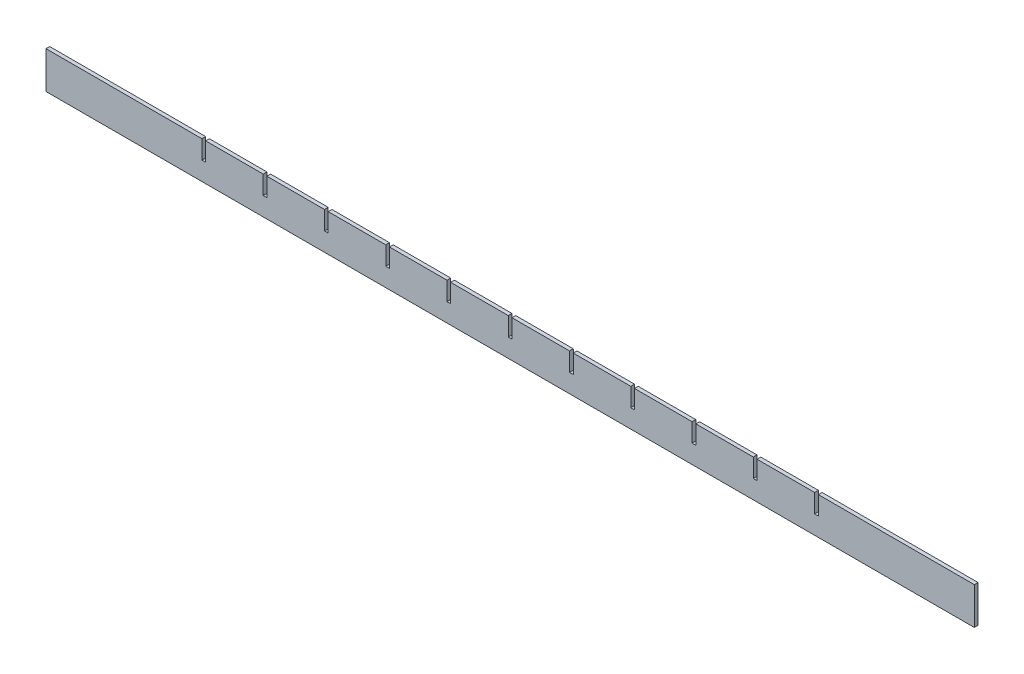
from build123d import *

# Parameters (mm, degrees)
ESQUISSE1_W                = 500
ESQUISSE1_H                = 20
BOSS_EXTRU_1_DEPTH         = 1
ESQUISSE2_W                = 2
ESQUISSE2_H                = 10
ENL_V_MAT_EXTRU_1_DEPTH    = 3
R_P_TITION_LIN_AIRE3_COUNT = 6
R_P_TITION_LIN_AIRE3_PITCH = 33
SYM_TRIE1_COPY_1_SKETCH_W  = 2
SYM_TRIE1_COPY_1_SKETCH_H  = 10
SYM_TRIE1_COPY_1_DEPTH     = 3
SYM_TRIE1_COPY_2_SKETCH_W  = 2
SYM_TRIE1_COPY_2_SKETCH_H  = 10
SYM_TRIE1_COPY_2_DEPTH     = 3
SYM_TRIE1_COPY_3_SKETCH_W  = 2
SYM_TRIE1_COPY_3_SKETCH_H  = 10
SYM_TRIE1_COPY_3_DEPTH     = 3
SYM_TRIE1_COPY_4_SKETCH_W  = 2
SYM_TRIE1_COPY_4_SKETCH_H  = 10
SYM_TRIE1_COPY_4_DEPTH     = 3
SYM_TRIE1_COPY_5_SKETCH_W  = 2
SYM_TRIE1_COPY_5_SKETCH_H  = 10
SYM_TRIE1_COPY_5_DEPTH     = 3
SYM_TRIE1_COPY_6_SKETCH_W  = 2
SYM_TRIE1_COPY_6_SKETCH_H  = 10
SYM_TRIE1_COPY_6_DEPTH     = 3


with BuildPart() as part:
    # Esquisse1 → Boss.-Extru.1 (new body, symmetric)
    with BuildSketch(Plane.XY):
        Rectangle(ESQUISSE1_W, ESQUISSE1_H)
    extrude(amount=BOSS_EXTRU_1_DEPTH, both=True)

    # Esquisse2 → Enlèv. mat.-Extru.1 (cut, through all)
    with BuildSketch(Plane.XY.offset(1)):
        with Locations((0, 5)):
            Rectangle(ESQUISSE2_W, ESQUISSE2_H)
    enl_v_mat_extru_1 = extrude(amount=-ENL_V_MAT_EXTRU_1_DEPTH, mode=Mode.SUBTRACT)

    # Répétition linéaire3: Enlèv. mat.-Extru.1 ×6
    with Locations(*[(-i * R_P_TITION_LIN_AIRE3_PITCH, 0, 0) for i in range(1, R_P_TITION_LIN_AIRE3_COUNT)]):
        add(enl_v_mat_extru_1, mode=Mode.SUBTRACT)

    # Symétrie1 copy 1 sketch → Symétrie1 copy 1 (cut, through all)
    with BuildSketch(Plane(origin=(33, 0, 1), x_dir=(-1, 0, 0), z_dir=(0, 0, 1))):
        with Locations((0, -5)):
            Rectangle(SYM_TRIE1_COPY_1_SKETCH_W, SYM_TRIE1_COPY_1_SKETCH_H)
    extrude(amount=-SYM_TRIE1_COPY_1_DEPTH, mode=Mode.SUBTRACT)

    # Symétrie1 copy 2 sketch → Symétrie1 copy 2 (cut, through all)
    with BuildSketch(Plane(origin=(66, 0, 1), x_dir=(-1, 0, 0), z_dir=(0, 0, 1))):
        with Locations((0, -5)):
            Rectangle(SYM_TRIE1_COPY_2_SKETCH_W, SYM_TRIE1_COPY_2_SKETCH_H)
    extrude(amount=-SYM_TRIE1_COPY_2_DEPTH, mode=Mode.SUBTRACT)

    # Symétrie1 copy 3 sketch → Symétrie1 copy 3 (cut, through all)
    with BuildSketch(Plane(origin=(99, 0, 1), x_dir=(-1, 0, 0), z_dir=(0, 0, 1))):
        with Locations((0, -5)):
            Rectangle(SYM_TRIE1_COPY_3_SKETCH_W, SYM_TRIE1_COPY_3_SKETCH_H)
    extrude(amount=-SYM_TRIE1_COPY_3_DEPTH, mode=Mode.SUBTRACT)

    # Symétrie1 copy 4 sketch → Symétrie1 copy 4 (cut, through all)
    with BuildSketch(Plane(origin=(132, 0, 1), x_dir=(-1, 0, 0), z_dir=(0, 0, 1))):
        with Locations((0, -5)):
            Rectangle(SYM_TRIE1_COPY_4_SKETCH_W, SYM_TRIE1_COPY_4_SKETCH_H)
    extrude(amount=-SYM_TRIE1_COPY_4_DEPTH, mode=Mode.SUBTRACT)

    # Symétrie1 copy 5 sketch → Symétrie1 copy 5 (cut, through all)
    with BuildSketch(Plane(origin=(165, 0, 1), x_dir=(-1, 0, 0), z_dir=(0, 0, 1))):
        with Locations((0, -5)):
            Rectangle(SYM_TRIE1_COPY_5_SKETCH_W, SYM_TRIE1_COPY_5_SKETCH_H)
    extrude(amount=-SYM_TRIE1_COPY_5_DEPTH, mode=Mode.SUBTRACT)

    # Symétrie1 copy 6 sketch → Symétrie1 copy 6 (cut, through all)
    with BuildSketch(Plane(origin=(0, 0, 1), x_dir=(-1, 0, 0), z_dir=(0, 0, 1))):
        with Locations((0, -5)):
            Rectangle(SYM_TRIE1_COPY_6_SKETCH_W, SYM_TRIE1_COPY_6_SKETCH_H)
    extrude(amount=-SYM_TRIE1_COPY_6_DEPTH, mode=Mode.SUBTRACT)


solid = part.part
